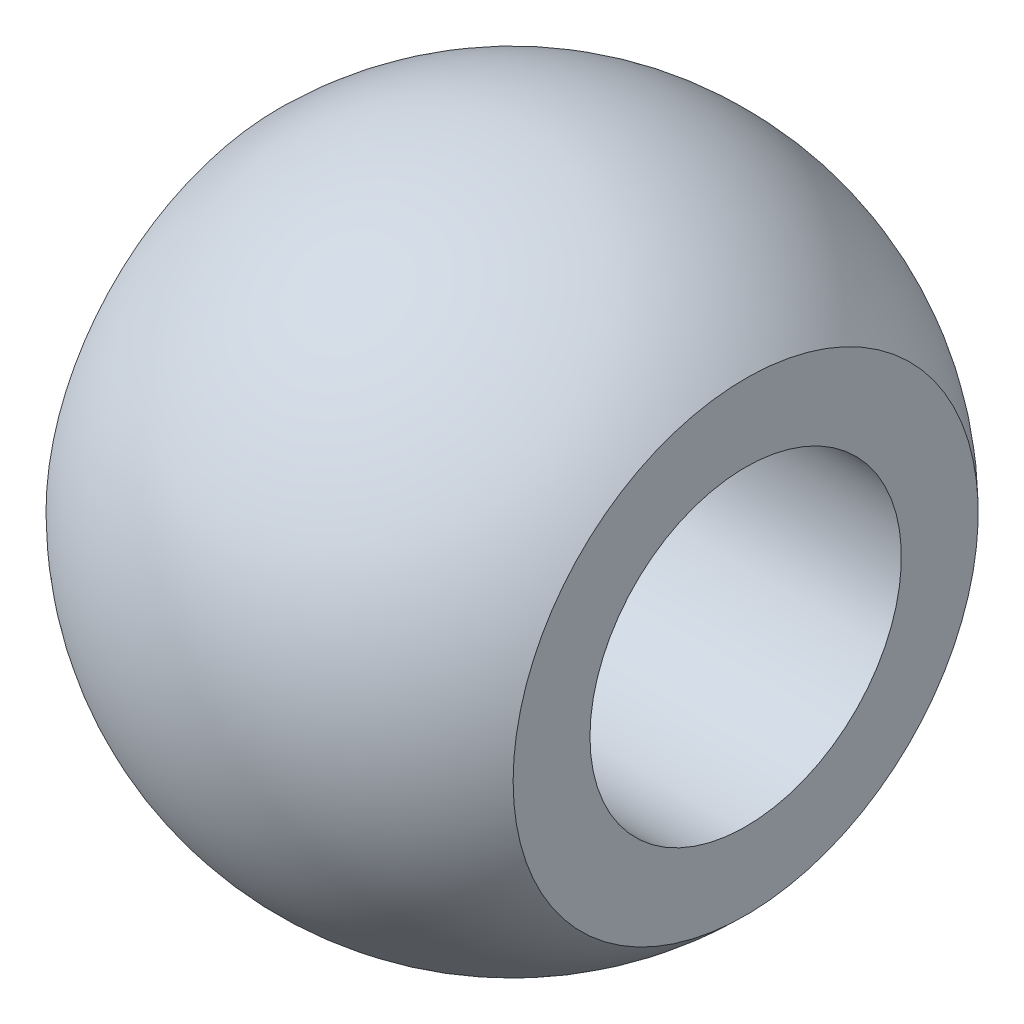
from build123d import *


with BuildPart() as part:
    # Sketch1 → Revolve1 (revolve)
    with BuildSketch(Plane.XY):
        with BuildLine():
            Line((4.5, 3), (4.5, 4.480234369))
            ThreePointArc((4.5, 4.480234369), (0, 6.35), (-4.5, 4.480234369))
            Line((-4.5, 4.480234369), (-4.5, 3))
            Line((-4.5, 3), (4.5, 3))
        make_face()
    revolve(axis=Axis((0, 0, 0), (1, 0, 0)))


solid = part.part
